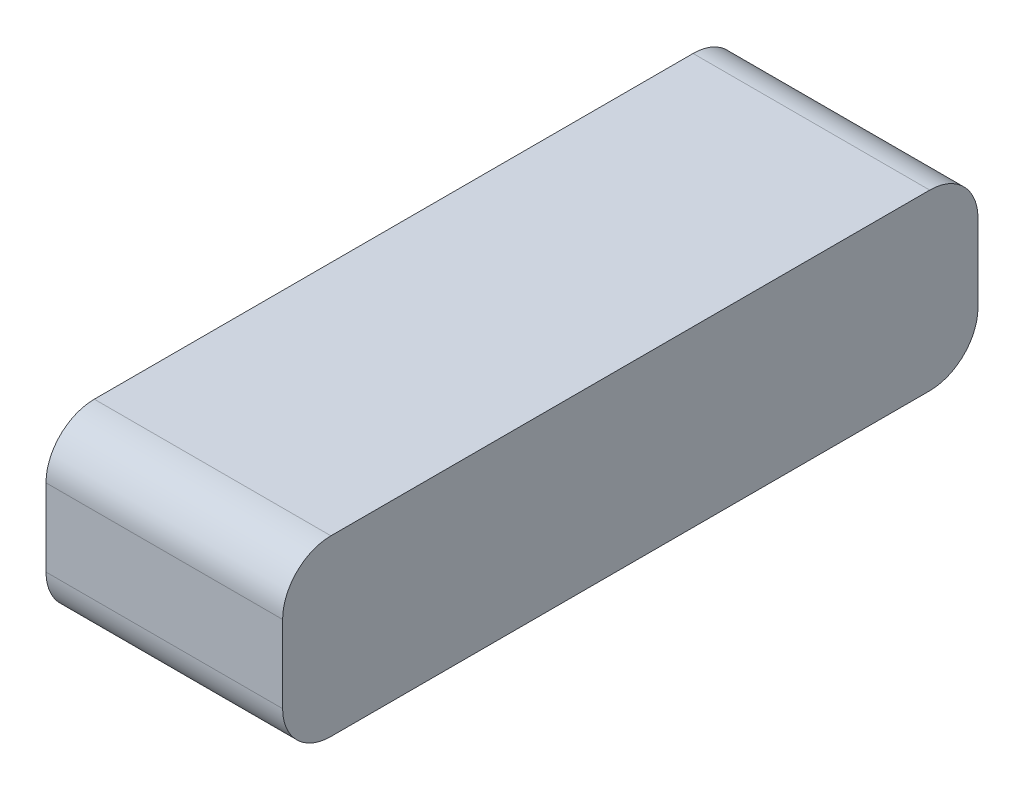
from build123d import *

# Parameters (mm, degrees)
SCHIZZO1_W                   = 49
SCHIZZO1_H                   = 36
ESTRUSIONE_ESTRUSIONE1_DEPTH = 144
RACCORDO1_R                  = 10


with BuildPart() as part:
    # Schizzo1 → Estrusione-Estrusione1 (new body)
    with BuildSketch(Plane.XY):
        Rectangle(SCHIZZO1_W, SCHIZZO1_H)
    extrude(amount=ESTRUSIONE_ESTRUSIONE1_DEPTH)

    # Raccordo1
    raccordo1_edges = [part.edges().sort_by_distance(p)[0] for p in [
        (0, -18, 144),
        (0, -18, 0),
        (0, 18, 0),
        (0, 18, 144),
    ]]
    fillet(raccordo1_edges, radius=RACCORDO1_R)


solid = part.part
